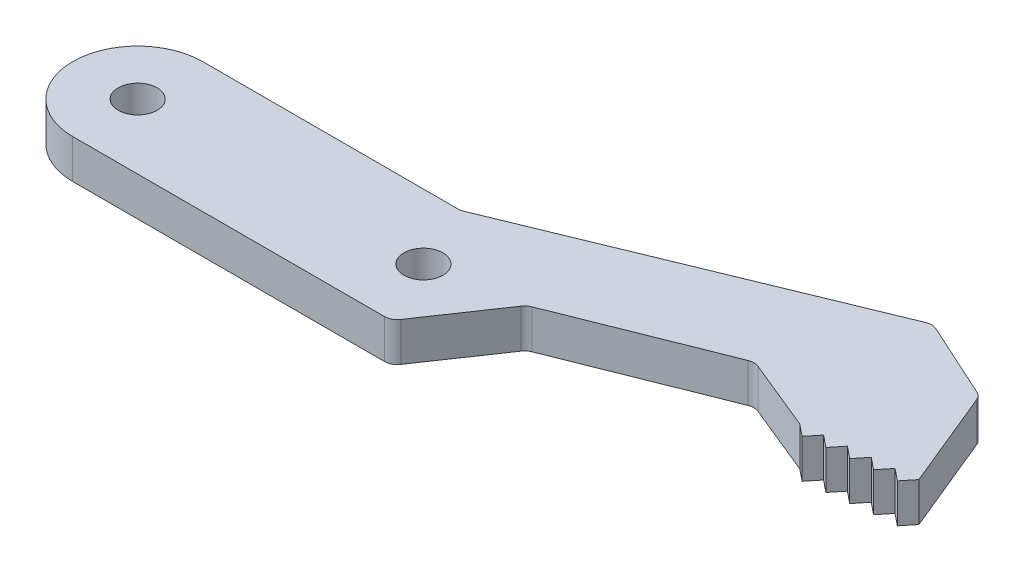
from build123d import *

# Parameters (mm, degrees)
SKETCH1_R           = 1.5
BOSS_EXTRUDE1_DEPTH = 3
SCALE1_SCALE        = 1.8


with BuildPart() as part:
    # Sketch1 → Boss-Extrude1 (new body)
    with BuildSketch(Plane(origin=(0, 0, 0), x_dir=(1, 0, 0), z_dir=(0, 1, 0))):
        with BuildLine():
            Line((0, -5), (23.998875872, -5))
            ThreePointArc((23.998875872, -5), (24.467345461, -4.883479623), (24.826642543, -4.561072489))
            Line((24.826642543, -4.561072489), (28.564941326, 0.954149161))
            ThreePointArc((28.564941326, 0.954149161), (28.766036178, 1.172359953), (29.022312673, 1.321950886))
            Line((29.022312673, 1.321950886), (40.929553216, 6.070049343))
            ThreePointArc((40.929553216, 6.070049343), (41.304486381, 6.141164834), (41.678758689, 6.066649533))
            Line((41.678758689, 6.066649533), (47.144586244, 3.829406729))
            Line((47.144586244, 3.829406729), (48.06174016, 3.086958957))
            Line((48.06174016, 3.086958957), (48.804187932, 4.004112872))
            Line((48.804187932, 4.004112872), (49.721341848, 3.2616651))
            Line((49.721341848, 3.2616651), (50.46378962, 4.178819016))
            Line((50.46378962, 4.178819016), (51.380943536, 3.436371244))
            Line((51.380943536, 3.436371244), (52.123391308, 4.35352516))
            Line((52.123391308, 4.35352516), (53.040545224, 3.611077387))
            Line((53.040545224, 3.611077387), (53.782992996, 4.528231303))
            Line((53.782992996, 4.528231303), (54.700146912, 3.785783531))
            Line((54.700146912, 3.785783531), (55.442594685, 4.702937447))
            Line((55.442594685, 4.702937447), (52.341745918, 12.244834503))
            ThreePointArc((52.341745918, 12.244834503), (52.137055639, 12.558350103), (51.831402108, 12.774604725))
            Line((51.831402108, 12.774604725), (46.024183924, 15.419882568))
            ThreePointArc((46.024183924, 15.419882568), (45.628323444, 15.509674561), (45.229386093, 15.434727162))
            Line((45.229386093, 15.434727162), (20.032711481, 5.075121772))
            ThreePointArc((20.032711481, 5.075121772), (19.846254378, 5.018960187), (19.652448068, 5))
            Line((19.652448068, 5), (0, 5))
            ThreePointArc((0, 5), (-5, 0), (0, -5))
        make_face()
        Circle(SKETCH1_R, mode=Mode.SUBTRACT)
        with Locations((22, 0)):
            Circle(SKETCH1_R, mode=Mode.SUBTRACT)
    extrude(amount=BOSS_EXTRUDE1_DEPTH)


with BuildPart() as part_1:
    # Scale1: scaled about (24.6084342, 1.5, -3.682524739)
    add(part.part.scale(SCALE1_SCALE).moved(Location((-19.68674736, -1.2, 2.946019791))))


solid = part_1.part
